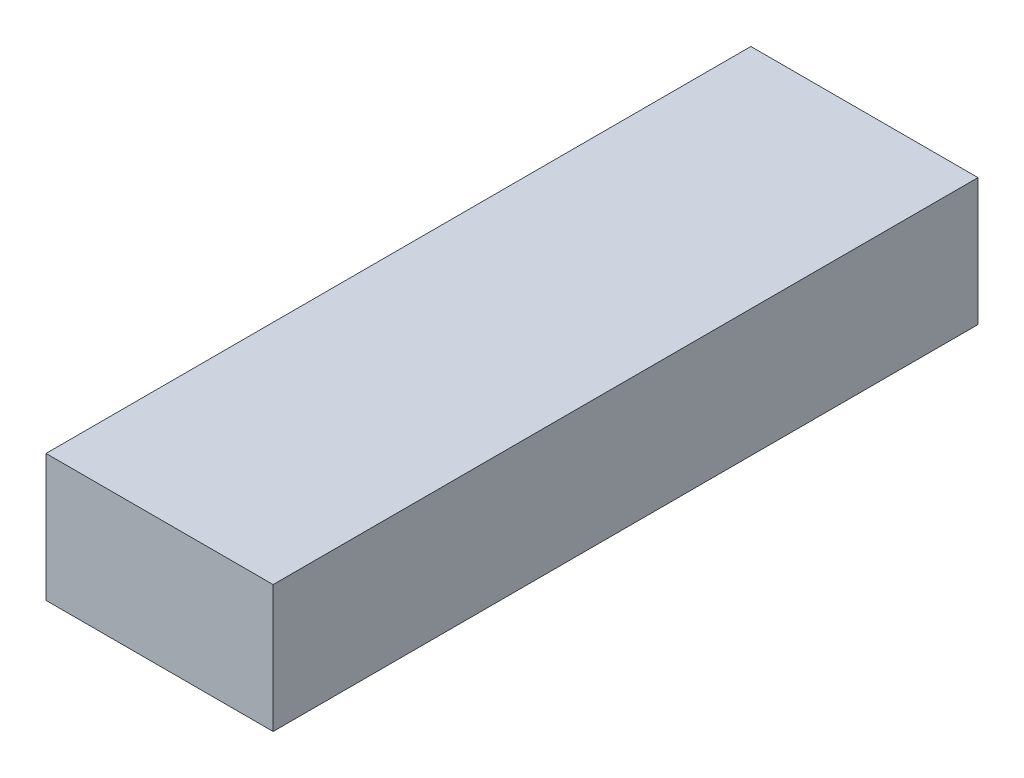
from build123d import *

# Parameters (mm, degrees)
SKETCH3_W           = 34.8
SKETCH3_H           = 108
BOSS_EXTRUDE1_DEPTH = 19.5


with BuildPart() as part:
    # Sketch3 → Boss-Extrude1 (new body)
    with BuildSketch(Plane(origin=(0, 0, 0), x_dir=(1, 0, 0), z_dir=(0, 1, 0))):
        Rectangle(SKETCH3_W, SKETCH3_H)
    extrude(amount=BOSS_EXTRUDE1_DEPTH)


solid = part.part
